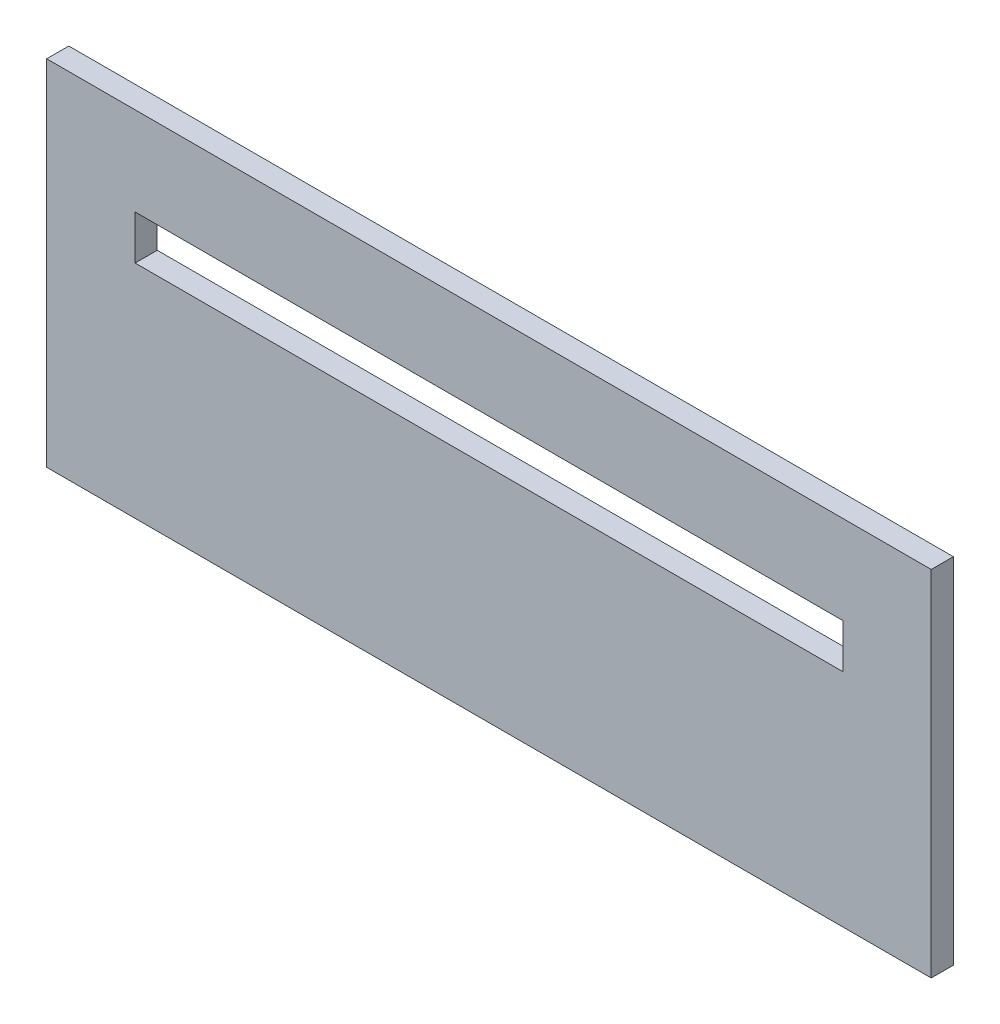
from build123d import *

# Parameters (mm, degrees)
SKETCH1_W           = 127
SKETCH1_H           = 50.8
BOSS_EXTRUDE1_DEPTH = 3.175
SKETCH2_W           = 101.6
SKETCH2_H           = 6.35
CUT_EXTRUDE1_DEPTH  = 3.175


with BuildPart() as part:
    # Sketch1 → Boss-Extrude1 (new body)
    with BuildSketch(Plane.XY):
        with Locations((34.455040737, 16.469248393)):
            Rectangle(SKETCH1_W, SKETCH1_H)
    extrude(amount=BOSS_EXTRUDE1_DEPTH)

    # Sketch2 → Cut-Extrude1 (cut)
    with BuildSketch(Plane.XY.offset(3.175)):
        with Locations((34.455040737, 25.994248393)):
            Rectangle(SKETCH2_W, SKETCH2_H)
    extrude(amount=-CUT_EXTRUDE1_DEPTH, mode=Mode.SUBTRACT)


solid = part.part
